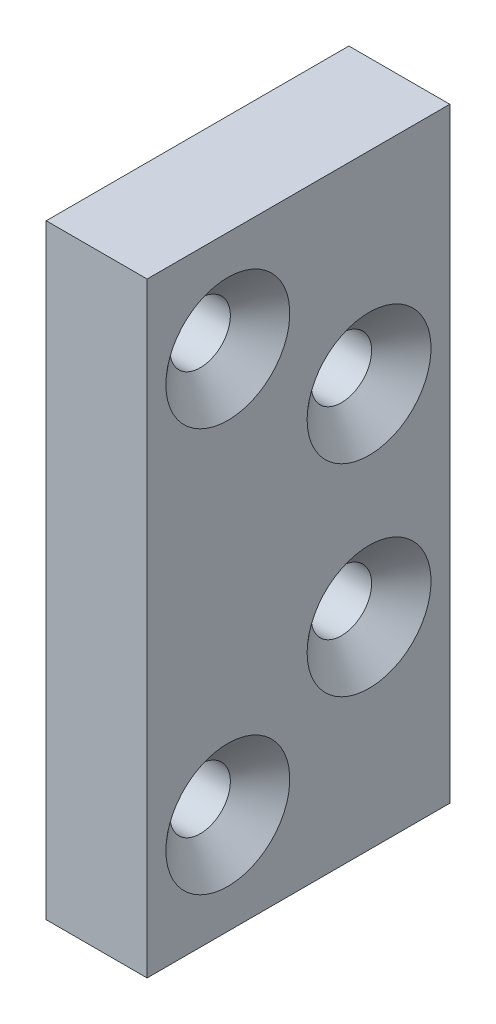
from build123d import *

# Parameters (mm, degrees)
SKETCH1_W           = 19.05
SKETCH1_H           = 38.1
SKETCH1_R           = 1.89865
BOSS_EXTRUDE1_DEPTH = 6.35
CHAMFER1_SIZE       = 2.00025
CHAMFER1_SIZE2      = 1.738790797


with BuildPart() as part:
    # Sketch1 → Boss-Extrude1 (new body)
    with BuildSketch(Plane(origin=(0, 0, 0), x_dir=(0, 0, -1), z_dir=(1, 0, 0))):
        Rectangle(SKETCH1_W, SKETCH1_H)
        with Locations((-4.445, 12.7)):
            Circle(SKETCH1_R, mode=Mode.SUBTRACT)
        with Locations((4.445, 6.35)):
            Circle(SKETCH1_R, mode=Mode.SUBTRACT)
        with Locations((-4.445, -12.7)):
            Circle(SKETCH1_R, mode=Mode.SUBTRACT)
        with Locations((4.445, -6.35)):
            Circle(SKETCH1_R, mode=Mode.SUBTRACT)
    extrude(amount=BOSS_EXTRUDE1_DEPTH)

    # Chamfer1
    chamfer1_edges = [part.edges().sort_by_distance(p)[0] for p in [
        (6.35, 12.7, 6.34365),
        (6.35, 6.35, -2.54635),
        (6.35, -12.7, 6.34365),
        (6.35, -6.35, -2.54635),
    ]]
    chamfer1_side = [part.faces().sort_by_distance(p)[0] for p in [
        (6.35, 0, 0),
    ]]
    chamfer(chamfer1_edges, length=CHAMFER1_SIZE, length2=CHAMFER1_SIZE2, reference=chamfer1_side[0])


solid = part.part
